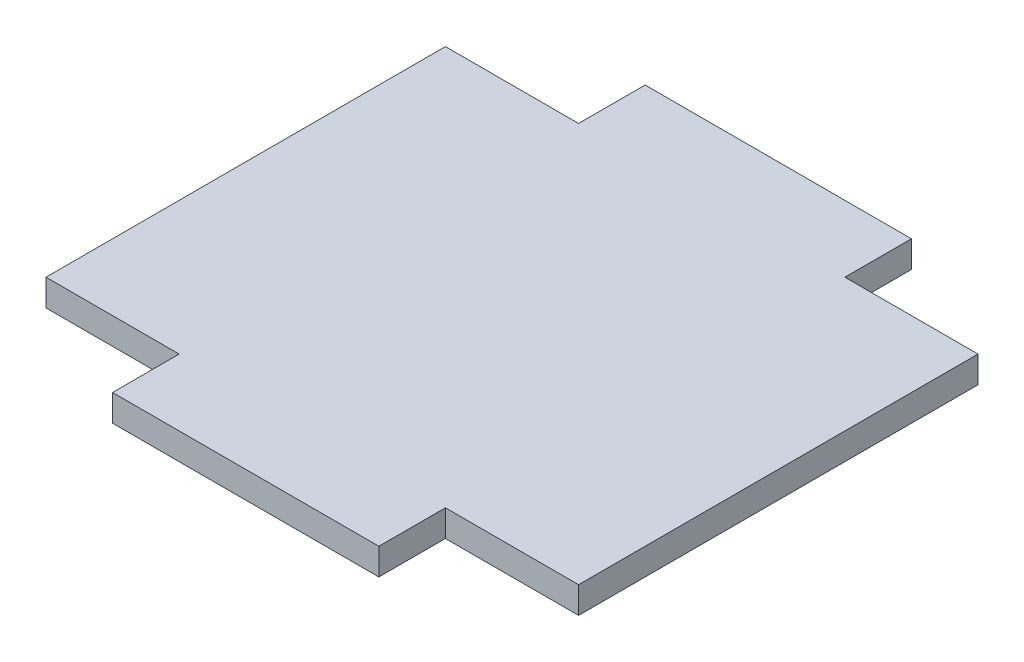
from build123d import *

# Parameters (mm, degrees)
SALIENTE_EXTRUIR2_DEPTH      = 1
SALIENTE_EXTRUIR2_DEPTH_BACK = 1
CROQUIS2_W                   = 1
CROQUIS2_H                   = 0.1
SALIENTE_EXTRUIR3_DEPTH      = 1
SALIENTE_EXTRUIR3_DEPTH_BACK = 1
CROQUIS3_W                   = 1.5
CROQUIS3_H                   = 0.1


with BuildPart() as part:
    # Croquis2 → Saliente-Extruir2 (new, two sides: drawn at the far end of the back side and taken through both)
    with BuildSketch(Plane.XY.offset(-SALIENTE_EXTRUIR2_DEPTH_BACK)):
        Rectangle(CROQUIS2_W, CROQUIS2_H)
    extrude(amount=SALIENTE_EXTRUIR2_DEPTH + SALIENTE_EXTRUIR2_DEPTH_BACK)

    # Croquis3 → Saliente-Extruir3 (add, two sides: drawn at the far end of the back side and taken through both)
    with BuildSketch(Plane(origin=(0, 0, 0), x_dir=(0, 0, -1), z_dir=(1, 0, 0)).offset(-SALIENTE_EXTRUIR3_DEPTH_BACK)):
        Rectangle(CROQUIS3_W, CROQUIS3_H)
    extrude(amount=SALIENTE_EXTRUIR3_DEPTH + SALIENTE_EXTRUIR3_DEPTH_BACK)


solid = part.part
